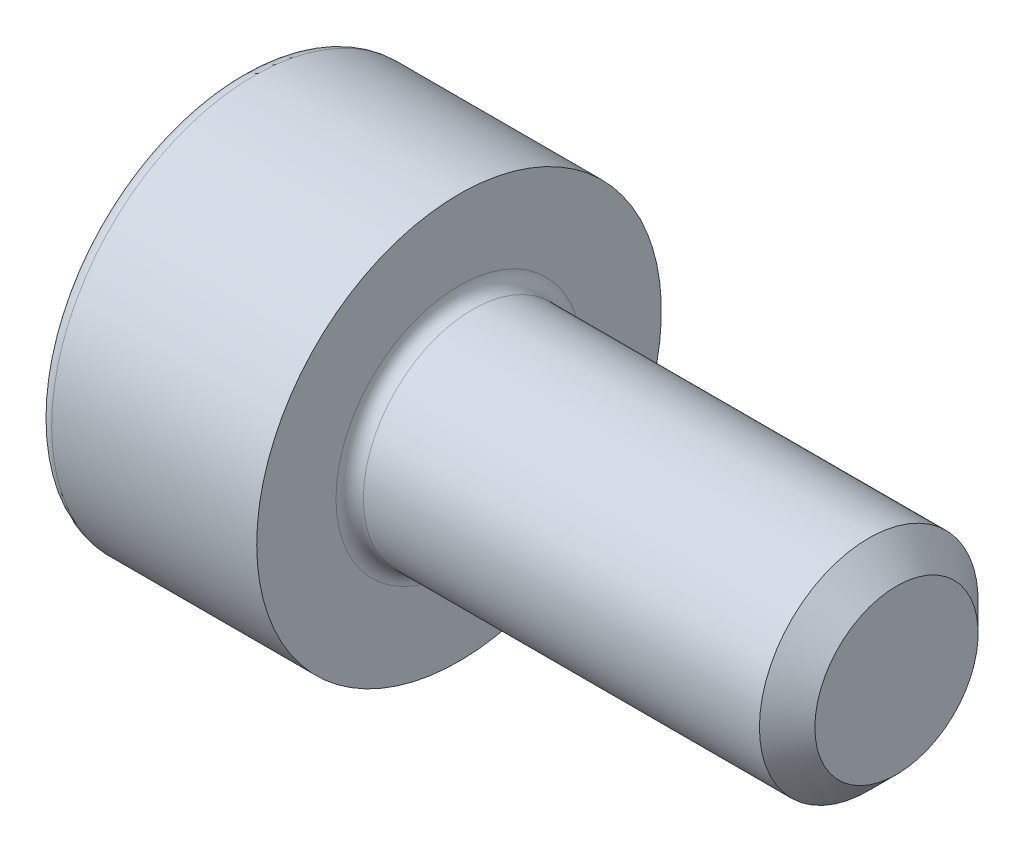
from build123d import *

# Parameters (mm, degrees)
CUT_EXTRUDE1_DEPTH = 1.1


with BuildPart() as part:
    # Sketch1 → Revolve1 (revolve)
    with BuildSketch(Plane.XY):
        with BuildLine():
            Line((3.7465, 1), (0.125, 1))
            ThreePointArc((0.125, 1), (0.036611652, 1.036611652), (0, 1.125))
            Line((0, 1.125), (0, 1.85))
            Line((0, 1.85), (-1.875, 1.85))
            ThreePointArc((-1.875, 1.85), (-1.963388348, 1.813388348), (-2, 1.725))
            Line((-2, 1.725), (-2, 0))
            Line((-2, 0), (4, 0))
            Line((4, 0), (4, 0.7465))
            Line((4, 0.7465), (3.7465, 1))
        make_face()
    revolve(axis=Axis((-2, 0, 0), (1, 0, 0)))

    # Sketch2 → Cut-Extrude1 (cut)
    with BuildSketch(Plane.ZY.offset(2)):
        Polygon((0.75, 0.433012702), (0, 0.866025404), (-0.75, 0.433012702), (-0.75, -0.433012702), (0, -0.866025404), (0.75, -0.433012702), align=None)
    extrude(amount=-CUT_EXTRUDE1_DEPTH, mode=Mode.SUBTRACT)


solid = part.part
